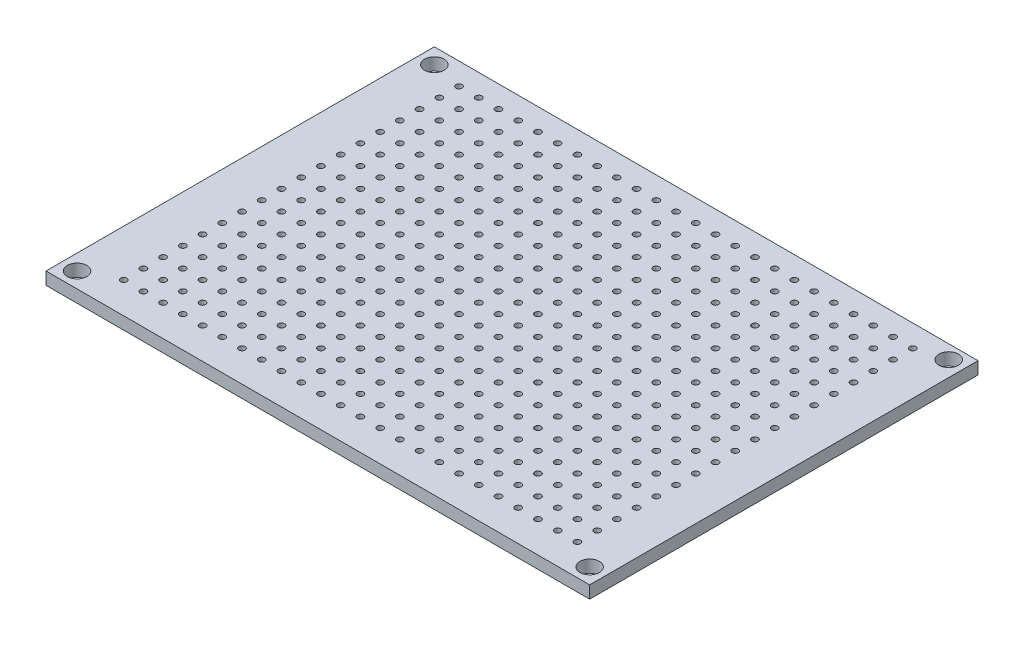
from build123d import *

# Parameters (mm, degrees)
SKETCH1_W           = 70
SKETCH1_H           = 50
BOSS_EXTRUDE1_DEPTH = 1.6
SKETCH2_R           = 1.25
SKETCH2_R_2         = 0.4
CUT_EXTRUDE1_DEPTH  = 2.6


with BuildPart() as part:
    # Sketch1 → Boss-Extrude1 (new body)
    with BuildSketch(Plane(origin=(0, 0, 0), x_dir=(1, 0, 0), z_dir=(0, 1, 0))):
        Rectangle(SKETCH1_W, SKETCH1_H)
    extrude(amount=BOSS_EXTRUDE1_DEPTH)

    # Sketch2 → Cut-Extrude1 (cut, through all)
    with BuildSketch(Plane(origin=(0, 1.6, 0), x_dir=(1, 0, 0), z_dir=(0, 1, 0))):
        with Locations((-33, 23)):
            Circle(SKETCH2_R)
        with Locations((-33, -23)):
            Circle(SKETCH2_R)
        with Locations((33, 23.22671073)):
            Circle(SKETCH2_R)
        with Locations((33, -23)):
            Circle(SKETCH2_R)
        with Locations((-29, -21)):
            Circle(SKETCH2_R_2)
        with Locations((-26.46, -21)):
            Circle(SKETCH2_R_2)
        with Locations((-23.92, -21)):
            Circle(SKETCH2_R_2)
        with Locations((-21.38, -21)):
            Circle(SKETCH2_R_2)
        with Locations((-18.84, -21)):
            Circle(SKETCH2_R_2)
        with Locations((-16.3, -21)):
            Circle(SKETCH2_R_2)
        with Locations((-13.76, -21)):
            Circle(SKETCH2_R_2)
        with Locations((-11.22, -21)):
            Circle(SKETCH2_R_2)
        with Locations((-8.68, -21)):
            Circle(SKETCH2_R_2)
        with Locations((-6.14, -21)):
            Circle(SKETCH2_R_2)
        with Locations((-3.6, -21)):
            Circle(SKETCH2_R_2)
        with Locations((-1.06, -21)):
            Circle(SKETCH2_R_2)
        with Locations((1.48, -21)):
            Circle(SKETCH2_R_2)
        with Locations((4.02, -21)):
            Circle(SKETCH2_R_2)
        with Locations((6.56, -21)):
            Circle(SKETCH2_R_2)
        with Locations((9.1, -21)):
            Circle(SKETCH2_R_2)
        with Locations((11.64, -21)):
            Circle(SKETCH2_R_2)
        with Locations((14.18, -21)):
            Circle(SKETCH2_R_2)
        with Locations((16.72, -21)):
            Circle(SKETCH2_R_2)
        with Locations((19.26, -21)):
            Circle(SKETCH2_R_2)
        with Locations((21.8, -21)):
            Circle(SKETCH2_R_2)
        with Locations((24.34, -21)):
            Circle(SKETCH2_R_2)
        with Locations((26.88, -21)):
            Circle(SKETCH2_R_2)
        with Locations((29.42, -21)):
            Circle(SKETCH2_R_2)
        with Locations((-26.46, -18.46)):
            Circle(SKETCH2_R_2)
        with Locations((-23.92, -18.46)):
            Circle(SKETCH2_R_2)
        with Locations((-21.38, -18.46)):
            Circle(SKETCH2_R_2)
        with Locations((-18.84, -18.46)):
            Circle(SKETCH2_R_2)
        with Locations((-16.3, -18.46)):
            Circle(SKETCH2_R_2)
        with Locations((-13.76, -18.46)):
            Circle(SKETCH2_R_2)
        with Locations((-11.22, -18.46)):
            Circle(SKETCH2_R_2)
        with Locations((-8.68, -18.46)):
            Circle(SKETCH2_R_2)
        with Locations((-6.14, -18.46)):
            Circle(SKETCH2_R_2)
        with Locations((-3.6, -18.46)):
            Circle(SKETCH2_R_2)
        with Locations((-1.06, -18.46)):
            Circle(SKETCH2_R_2)
        with Locations((1.48, -18.46)):
            Circle(SKETCH2_R_2)
        with Locations((4.02, -18.46)):
            Circle(SKETCH2_R_2)
        with Locations((6.56, -18.46)):
            Circle(SKETCH2_R_2)
        with Locations((9.1, -18.46)):
            Circle(SKETCH2_R_2)
        with Locations((11.64, -18.46)):
            Circle(SKETCH2_R_2)
        with Locations((14.18, -18.46)):
            Circle(SKETCH2_R_2)
        with Locations((16.72, -18.46)):
            Circle(SKETCH2_R_2)
        with Locations((19.26, -18.46)):
            Circle(SKETCH2_R_2)
        with Locations((21.8, -18.46)):
            Circle(SKETCH2_R_2)
        with Locations((24.34, -18.46)):
            Circle(SKETCH2_R_2)
        with Locations((26.88, -18.46)):
            Circle(SKETCH2_R_2)
        with Locations((29.42, -18.46)):
            Circle(SKETCH2_R_2)
        with Locations((-26.46, -15.92)):
            Circle(SKETCH2_R_2)
        with Locations((-23.92, -15.92)):
            Circle(SKETCH2_R_2)
        with Locations((-21.38, -15.92)):
            Circle(SKETCH2_R_2)
        with Locations((-18.84, -15.92)):
            Circle(SKETCH2_R_2)
        with Locations((-16.3, -15.92)):
            Circle(SKETCH2_R_2)
        with Locations((-13.76, -15.92)):
            Circle(SKETCH2_R_2)
        with Locations((-11.22, -15.92)):
            Circle(SKETCH2_R_2)
        with Locations((-8.68, -15.92)):
            Circle(SKETCH2_R_2)
        with Locations((-6.14, -15.92)):
            Circle(SKETCH2_R_2)
        with Locations((-3.6, -15.92)):
            Circle(SKETCH2_R_2)
        with Locations((-1.06, -15.92)):
            Circle(SKETCH2_R_2)
        with Locations((1.48, -15.92)):
            Circle(SKETCH2_R_2)
        with Locations((4.02, -15.92)):
            Circle(SKETCH2_R_2)
        with Locations((6.56, -15.92)):
            Circle(SKETCH2_R_2)
        with Locations((9.1, -15.92)):
            Circle(SKETCH2_R_2)
        with Locations((11.64, -15.92)):
            Circle(SKETCH2_R_2)
        with Locations((14.18, -15.92)):
            Circle(SKETCH2_R_2)
        with Locations((16.72, -15.92)):
            Circle(SKETCH2_R_2)
        with Locations((19.26, -15.92)):
            Circle(SKETCH2_R_2)
        with Locations((21.8, -15.92)):
            Circle(SKETCH2_R_2)
        with Locations((24.34, -15.92)):
            Circle(SKETCH2_R_2)
        with Locations((26.88, -15.92)):
            Circle(SKETCH2_R_2)
        with Locations((29.42, -15.92)):
            Circle(SKETCH2_R_2)
        with Locations((-26.46, -13.38)):
            Circle(SKETCH2_R_2)
        with Locations((-23.92, -13.38)):
            Circle(SKETCH2_R_2)
        with Locations((-21.38, -13.38)):
            Circle(SKETCH2_R_2)
        with Locations((-18.84, -13.38)):
            Circle(SKETCH2_R_2)
        with Locations((-16.3, -13.38)):
            Circle(SKETCH2_R_2)
        with Locations((-13.76, -13.38)):
            Circle(SKETCH2_R_2)
        with Locations((-11.22, -13.38)):
            Circle(SKETCH2_R_2)
        with Locations((-8.68, -13.38)):
            Circle(SKETCH2_R_2)
        with Locations((-6.14, -13.38)):
            Circle(SKETCH2_R_2)
        with Locations((-3.6, -13.38)):
            Circle(SKETCH2_R_2)
        with Locations((-1.06, -13.38)):
            Circle(SKETCH2_R_2)
        with Locations((1.48, -13.38)):
            Circle(SKETCH2_R_2)
        with Locations((4.02, -13.38)):
            Circle(SKETCH2_R_2)
        with Locations((6.56, -13.38)):
            Circle(SKETCH2_R_2)
        with Locations((9.1, -13.38)):
            Circle(SKETCH2_R_2)
        with Locations((11.64, -13.38)):
            Circle(SKETCH2_R_2)
        with Locations((14.18, -13.38)):
            Circle(SKETCH2_R_2)
        with Locations((16.72, -13.38)):
            Circle(SKETCH2_R_2)
        with Locations((19.26, -13.38)):
            Circle(SKETCH2_R_2)
        with Locations((21.8, -13.38)):
            Circle(SKETCH2_R_2)
        with Locations((24.34, -13.38)):
            Circle(SKETCH2_R_2)
        with Locations((26.88, -13.38)):
            Circle(SKETCH2_R_2)
        with Locations((29.42, -13.38)):
            Circle(SKETCH2_R_2)
        with Locations((-26.46, -10.84)):
            Circle(SKETCH2_R_2)
        with Locations((-23.92, -10.84)):
            Circle(SKETCH2_R_2)
        with Locations((-21.38, -10.84)):
            Circle(SKETCH2_R_2)
        with Locations((-18.84, -10.84)):
            Circle(SKETCH2_R_2)
        with Locations((-16.3, -10.84)):
            Circle(SKETCH2_R_2)
        with Locations((-13.76, -10.84)):
            Circle(SKETCH2_R_2)
        with Locations((-11.22, -10.84)):
            Circle(SKETCH2_R_2)
        with Locations((-8.68, -10.84)):
            Circle(SKETCH2_R_2)
        with Locations((-6.14, -10.84)):
            Circle(SKETCH2_R_2)
        with Locations((-3.6, -10.84)):
            Circle(SKETCH2_R_2)
        with Locations((-1.06, -10.84)):
            Circle(SKETCH2_R_2)
        with Locations((1.48, -10.84)):
            Circle(SKETCH2_R_2)
        with Locations((4.02, -10.84)):
            Circle(SKETCH2_R_2)
        with Locations((6.56, -10.84)):
            Circle(SKETCH2_R_2)
        with Locations((9.1, -10.84)):
            Circle(SKETCH2_R_2)
        with Locations((11.64, -10.84)):
            Circle(SKETCH2_R_2)
        with Locations((14.18, -10.84)):
            Circle(SKETCH2_R_2)
        with Locations((16.72, -10.84)):
            Circle(SKETCH2_R_2)
        with Locations((19.26, -10.84)):
            Circle(SKETCH2_R_2)
        with Locations((21.8, -10.84)):
            Circle(SKETCH2_R_2)
        with Locations((24.34, -10.84)):
            Circle(SKETCH2_R_2)
        with Locations((26.88, -10.84)):
            Circle(SKETCH2_R_2)
        with Locations((29.42, -10.84)):
            Circle(SKETCH2_R_2)
        with Locations((-26.46, -8.3)):
            Circle(SKETCH2_R_2)
        with Locations((-23.92, -8.3)):
            Circle(SKETCH2_R_2)
        with Locations((-21.38, -8.3)):
            Circle(SKETCH2_R_2)
        with Locations((-18.84, -8.3)):
            Circle(SKETCH2_R_2)
        with Locations((-16.3, -8.3)):
            Circle(SKETCH2_R_2)
        with Locations((-13.76, -8.3)):
            Circle(SKETCH2_R_2)
        with Locations((-11.22, -8.3)):
            Circle(SKETCH2_R_2)
        with Locations((-8.68, -8.3)):
            Circle(SKETCH2_R_2)
        with Locations((-6.14, -8.3)):
            Circle(SKETCH2_R_2)
        with Locations((-3.6, -8.3)):
            Circle(SKETCH2_R_2)
        with Locations((-1.06, -8.3)):
            Circle(SKETCH2_R_2)
        with Locations((1.48, -8.3)):
            Circle(SKETCH2_R_2)
        with Locations((4.02, -8.3)):
            Circle(SKETCH2_R_2)
        with Locations((6.56, -8.3)):
            Circle(SKETCH2_R_2)
        with Locations((9.1, -8.3)):
            Circle(SKETCH2_R_2)
        with Locations((11.64, -8.3)):
            Circle(SKETCH2_R_2)
        with Locations((14.18, -8.3)):
            Circle(SKETCH2_R_2)
        with Locations((16.72, -8.3)):
            Circle(SKETCH2_R_2)
        with Locations((19.26, -8.3)):
            Circle(SKETCH2_R_2)
        with Locations((21.8, -8.3)):
            Circle(SKETCH2_R_2)
        with Locations((24.34, -8.3)):
            Circle(SKETCH2_R_2)
        with Locations((26.88, -8.3)):
            Circle(SKETCH2_R_2)
        with Locations((29.42, -8.3)):
            Circle(SKETCH2_R_2)
        with Locations((-26.46, -5.76)):
            Circle(SKETCH2_R_2)
        with Locations((-23.92, -5.76)):
            Circle(SKETCH2_R_2)
        with Locations((-21.38, -5.76)):
            Circle(SKETCH2_R_2)
        with Locations((-18.84, -5.76)):
            Circle(SKETCH2_R_2)
        with Locations((-16.3, -5.76)):
            Circle(SKETCH2_R_2)
        with Locations((-13.76, -5.76)):
            Circle(SKETCH2_R_2)
        with Locations((-11.22, -5.76)):
            Circle(SKETCH2_R_2)
        with Locations((-8.68, -5.76)):
            Circle(SKETCH2_R_2)
        with Locations((-6.14, -5.76)):
            Circle(SKETCH2_R_2)
        with Locations((-3.6, -5.76)):
            Circle(SKETCH2_R_2)
        with Locations((-1.06, -5.76)):
            Circle(SKETCH2_R_2)
        with Locations((1.48, -5.76)):
            Circle(SKETCH2_R_2)
        with Locations((4.02, -5.76)):
            Circle(SKETCH2_R_2)
        with Locations((6.56, -5.76)):
            Circle(SKETCH2_R_2)
        with Locations((9.1, -5.76)):
            Circle(SKETCH2_R_2)
        with Locations((11.64, -5.76)):
            Circle(SKETCH2_R_2)
        with Locations((14.18, -5.76)):
            Circle(SKETCH2_R_2)
        with Locations((16.72, -5.76)):
            Circle(SKETCH2_R_2)
        with Locations((19.26, -5.76)):
            Circle(SKETCH2_R_2)
        with Locations((21.8, -5.76)):
            Circle(SKETCH2_R_2)
        with Locations((24.34, -5.76)):
            Circle(SKETCH2_R_2)
        with Locations((26.88, -5.76)):
            Circle(SKETCH2_R_2)
        with Locations((29.42, -5.76)):
            Circle(SKETCH2_R_2)
        with Locations((-26.46, -3.22)):
            Circle(SKETCH2_R_2)
        with Locations((-23.92, -3.22)):
            Circle(SKETCH2_R_2)
        with Locations((-21.38, -3.22)):
            Circle(SKETCH2_R_2)
        with Locations((-18.84, -3.22)):
            Circle(SKETCH2_R_2)
        with Locations((-16.3, -3.22)):
            Circle(SKETCH2_R_2)
        with Locations((-13.76, -3.22)):
            Circle(SKETCH2_R_2)
        with Locations((-11.22, -3.22)):
            Circle(SKETCH2_R_2)
        with Locations((-8.68, -3.22)):
            Circle(SKETCH2_R_2)
        with Locations((-6.14, -3.22)):
            Circle(SKETCH2_R_2)
        with Locations((-3.6, -3.22)):
            Circle(SKETCH2_R_2)
        with Locations((-1.06, -3.22)):
            Circle(SKETCH2_R_2)
        with Locations((1.48, -3.22)):
            Circle(SKETCH2_R_2)
        with Locations((4.02, -3.22)):
            Circle(SKETCH2_R_2)
        with Locations((6.56, -3.22)):
            Circle(SKETCH2_R_2)
        with Locations((9.1, -3.22)):
            Circle(SKETCH2_R_2)
        with Locations((11.64, -3.22)):
            Circle(SKETCH2_R_2)
        with Locations((14.18, -3.22)):
            Circle(SKETCH2_R_2)
        with Locations((16.72, -3.22)):
            Circle(SKETCH2_R_2)
        with Locations((19.26, -3.22)):
            Circle(SKETCH2_R_2)
        with Locations((21.8, -3.22)):
            Circle(SKETCH2_R_2)
        with Locations((24.34, -3.22)):
            Circle(SKETCH2_R_2)
        with Locations((26.88, -3.22)):
            Circle(SKETCH2_R_2)
        with Locations((29.42, -3.22)):
            Circle(SKETCH2_R_2)
        with Locations((-26.46, -0.68)):
            Circle(SKETCH2_R_2)
        with Locations((-23.92, -0.68)):
            Circle(SKETCH2_R_2)
        with Locations((-21.38, -0.68)):
            Circle(SKETCH2_R_2)
        with Locations((-18.84, -0.68)):
            Circle(SKETCH2_R_2)
        with Locations((-16.3, -0.68)):
            Circle(SKETCH2_R_2)
        with Locations((-13.76, -0.68)):
            Circle(SKETCH2_R_2)
        with Locations((-11.22, -0.68)):
            Circle(SKETCH2_R_2)
        with Locations((-8.68, -0.68)):
            Circle(SKETCH2_R_2)
        with Locations((-6.14, -0.68)):
            Circle(SKETCH2_R_2)
        with Locations((-3.6, -0.68)):
            Circle(SKETCH2_R_2)
        with Locations((-1.06, -0.68)):
            Circle(SKETCH2_R_2)
        with Locations((1.48, -0.68)):
            Circle(SKETCH2_R_2)
        with Locations((4.02, -0.68)):
            Circle(SKETCH2_R_2)
        with Locations((6.56, -0.68)):
            Circle(SKETCH2_R_2)
        with Locations((9.1, -0.68)):
            Circle(SKETCH2_R_2)
        with Locations((11.64, -0.68)):
            Circle(SKETCH2_R_2)
        with Locations((14.18, -0.68)):
            Circle(SKETCH2_R_2)
        with Locations((16.72, -0.68)):
            Circle(SKETCH2_R_2)
        with Locations((19.26, -0.68)):
            Circle(SKETCH2_R_2)
        with Locations((21.8, -0.68)):
            Circle(SKETCH2_R_2)
        with Locations((24.34, -0.68)):
            Circle(SKETCH2_R_2)
        with Locations((26.88, -0.68)):
            Circle(SKETCH2_R_2)
        with Locations((29.42, -0.68)):
            Circle(SKETCH2_R_2)
        with Locations((-26.46, 1.86)):
            Circle(SKETCH2_R_2)
        with Locations((-23.92, 1.86)):
            Circle(SKETCH2_R_2)
        with Locations((-21.38, 1.86)):
            Circle(SKETCH2_R_2)
        with Locations((-18.84, 1.86)):
            Circle(SKETCH2_R_2)
        with Locations((-16.3, 1.86)):
            Circle(SKETCH2_R_2)
        with Locations((-13.76, 1.86)):
            Circle(SKETCH2_R_2)
        with Locations((-11.22, 1.86)):
            Circle(SKETCH2_R_2)
        with Locations((-8.68, 1.86)):
            Circle(SKETCH2_R_2)
        with Locations((-6.14, 1.86)):
            Circle(SKETCH2_R_2)
        with Locations((-3.6, 1.86)):
            Circle(SKETCH2_R_2)
        with Locations((-1.06, 1.86)):
            Circle(SKETCH2_R_2)
        with Locations((1.48, 1.86)):
            Circle(SKETCH2_R_2)
        with Locations((4.02, 1.86)):
            Circle(SKETCH2_R_2)
        with Locations((6.56, 1.86)):
            Circle(SKETCH2_R_2)
        with Locations((9.1, 1.86)):
            Circle(SKETCH2_R_2)
        with Locations((11.64, 1.86)):
            Circle(SKETCH2_R_2)
        with Locations((14.18, 1.86)):
            Circle(SKETCH2_R_2)
        with Locations((16.72, 1.86)):
            Circle(SKETCH2_R_2)
        with Locations((19.26, 1.86)):
            Circle(SKETCH2_R_2)
        with Locations((21.8, 1.86)):
            Circle(SKETCH2_R_2)
        with Locations((24.34, 1.86)):
            Circle(SKETCH2_R_2)
        with Locations((26.88, 1.86)):
            Circle(SKETCH2_R_2)
        with Locations((29.42, 1.86)):
            Circle(SKETCH2_R_2)
        with Locations((-26.46, 4.4)):
            Circle(SKETCH2_R_2)
        with Locations((-23.92, 4.4)):
            Circle(SKETCH2_R_2)
        with Locations((-21.38, 4.4)):
            Circle(SKETCH2_R_2)
        with Locations((-18.84, 4.4)):
            Circle(SKETCH2_R_2)
        with Locations((-16.3, 4.4)):
            Circle(SKETCH2_R_2)
        with Locations((-13.76, 4.4)):
            Circle(SKETCH2_R_2)
        with Locations((-11.22, 4.4)):
            Circle(SKETCH2_R_2)
        with Locations((-8.68, 4.4)):
            Circle(SKETCH2_R_2)
        with Locations((-6.14, 4.4)):
            Circle(SKETCH2_R_2)
        with Locations((-3.6, 4.4)):
            Circle(SKETCH2_R_2)
        with Locations((-1.06, 4.4)):
            Circle(SKETCH2_R_2)
        with Locations((1.48, 4.4)):
            Circle(SKETCH2_R_2)
        with Locations((4.02, 4.4)):
            Circle(SKETCH2_R_2)
        with Locations((6.56, 4.4)):
            Circle(SKETCH2_R_2)
        with Locations((9.1, 4.4)):
            Circle(SKETCH2_R_2)
        with Locations((11.64, 4.4)):
            Circle(SKETCH2_R_2)
        with Locations((14.18, 4.4)):
            Circle(SKETCH2_R_2)
        with Locations((16.72, 4.4)):
            Circle(SKETCH2_R_2)
        with Locations((19.26, 4.4)):
            Circle(SKETCH2_R_2)
        with Locations((21.8, 4.4)):
            Circle(SKETCH2_R_2)
        with Locations((24.34, 4.4)):
            Circle(SKETCH2_R_2)
        with Locations((26.88, 4.4)):
            Circle(SKETCH2_R_2)
        with Locations((29.42, 4.4)):
            Circle(SKETCH2_R_2)
        with Locations((-26.46, 6.94)):
            Circle(SKETCH2_R_2)
        with Locations((-23.92, 6.94)):
            Circle(SKETCH2_R_2)
        with Locations((-21.38, 6.94)):
            Circle(SKETCH2_R_2)
        with Locations((-18.84, 6.94)):
            Circle(SKETCH2_R_2)
        with Locations((-16.3, 6.94)):
            Circle(SKETCH2_R_2)
        with Locations((-13.76, 6.94)):
            Circle(SKETCH2_R_2)
        with Locations((-11.22, 6.94)):
            Circle(SKETCH2_R_2)
        with Locations((-8.68, 6.94)):
            Circle(SKETCH2_R_2)
        with Locations((-6.14, 6.94)):
            Circle(SKETCH2_R_2)
        with Locations((-3.6, 6.94)):
            Circle(SKETCH2_R_2)
        with Locations((-1.06, 6.94)):
            Circle(SKETCH2_R_2)
        with Locations((1.48, 6.94)):
            Circle(SKETCH2_R_2)
        with Locations((4.02, 6.94)):
            Circle(SKETCH2_R_2)
        with Locations((6.56, 6.94)):
            Circle(SKETCH2_R_2)
        with Locations((9.1, 6.94)):
            Circle(SKETCH2_R_2)
        with Locations((11.64, 6.94)):
            Circle(SKETCH2_R_2)
        with Locations((14.18, 6.94)):
            Circle(SKETCH2_R_2)
        with Locations((16.72, 6.94)):
            Circle(SKETCH2_R_2)
        with Locations((19.26, 6.94)):
            Circle(SKETCH2_R_2)
        with Locations((21.8, 6.94)):
            Circle(SKETCH2_R_2)
        with Locations((24.34, 6.94)):
            Circle(SKETCH2_R_2)
        with Locations((26.88, 6.94)):
            Circle(SKETCH2_R_2)
        with Locations((29.42, 6.94)):
            Circle(SKETCH2_R_2)
        with Locations((-26.46, 9.48)):
            Circle(SKETCH2_R_2)
        with Locations((-23.92, 9.48)):
            Circle(SKETCH2_R_2)
        with Locations((-21.38, 9.48)):
            Circle(SKETCH2_R_2)
        with Locations((-18.84, 9.48)):
            Circle(SKETCH2_R_2)
        with Locations((-16.3, 9.48)):
            Circle(SKETCH2_R_2)
        with Locations((-13.76, 9.48)):
            Circle(SKETCH2_R_2)
        with Locations((-11.22, 9.48)):
            Circle(SKETCH2_R_2)
        with Locations((-8.68, 9.48)):
            Circle(SKETCH2_R_2)
        with Locations((-6.14, 9.48)):
            Circle(SKETCH2_R_2)
        with Locations((-3.6, 9.48)):
            Circle(SKETCH2_R_2)
        with Locations((-1.06, 9.48)):
            Circle(SKETCH2_R_2)
        with Locations((1.48, 9.48)):
            Circle(SKETCH2_R_2)
        with Locations((4.02, 9.48)):
            Circle(SKETCH2_R_2)
        with Locations((6.56, 9.48)):
            Circle(SKETCH2_R_2)
        with Locations((9.1, 9.48)):
            Circle(SKETCH2_R_2)
        with Locations((11.64, 9.48)):
            Circle(SKETCH2_R_2)
        with Locations((14.18, 9.48)):
            Circle(SKETCH2_R_2)
        with Locations((16.72, 9.48)):
            Circle(SKETCH2_R_2)
        with Locations((19.26, 9.48)):
            Circle(SKETCH2_R_2)
        with Locations((21.8, 9.48)):
            Circle(SKETCH2_R_2)
        with Locations((24.34, 9.48)):
            Circle(SKETCH2_R_2)
        with Locations((26.88, 9.48)):
            Circle(SKETCH2_R_2)
        with Locations((29.42, 9.48)):
            Circle(SKETCH2_R_2)
        with Locations((-26.46, 12.02)):
            Circle(SKETCH2_R_2)
        with Locations((-23.92, 12.02)):
            Circle(SKETCH2_R_2)
        with Locations((-21.38, 12.02)):
            Circle(SKETCH2_R_2)
        with Locations((-18.84, 12.02)):
            Circle(SKETCH2_R_2)
        with Locations((-16.3, 12.02)):
            Circle(SKETCH2_R_2)
        with Locations((-13.76, 12.02)):
            Circle(SKETCH2_R_2)
        with Locations((-11.22, 12.02)):
            Circle(SKETCH2_R_2)
        with Locations((-8.68, 12.02)):
            Circle(SKETCH2_R_2)
        with Locations((-6.14, 12.02)):
            Circle(SKETCH2_R_2)
        with Locations((-3.6, 12.02)):
            Circle(SKETCH2_R_2)
        with Locations((-1.06, 12.02)):
            Circle(SKETCH2_R_2)
        with Locations((1.48, 12.02)):
            Circle(SKETCH2_R_2)
        with Locations((4.02, 12.02)):
            Circle(SKETCH2_R_2)
        with Locations((6.56, 12.02)):
            Circle(SKETCH2_R_2)
        with Locations((9.1, 12.02)):
            Circle(SKETCH2_R_2)
        with Locations((11.64, 12.02)):
            Circle(SKETCH2_R_2)
        with Locations((14.18, 12.02)):
            Circle(SKETCH2_R_2)
        with Locations((16.72, 12.02)):
            Circle(SKETCH2_R_2)
        with Locations((19.26, 12.02)):
            Circle(SKETCH2_R_2)
        with Locations((21.8, 12.02)):
            Circle(SKETCH2_R_2)
        with Locations((24.34, 12.02)):
            Circle(SKETCH2_R_2)
        with Locations((26.88, 12.02)):
            Circle(SKETCH2_R_2)
        with Locations((29.42, 12.02)):
            Circle(SKETCH2_R_2)
        with Locations((-26.46, 14.56)):
            Circle(SKETCH2_R_2)
        with Locations((-23.92, 14.56)):
            Circle(SKETCH2_R_2)
        with Locations((-21.38, 14.56)):
            Circle(SKETCH2_R_2)
        with Locations((-18.84, 14.56)):
            Circle(SKETCH2_R_2)
        with Locations((-16.3, 14.56)):
            Circle(SKETCH2_R_2)
        with Locations((-13.76, 14.56)):
            Circle(SKETCH2_R_2)
        with Locations((-11.22, 14.56)):
            Circle(SKETCH2_R_2)
        with Locations((-8.68, 14.56)):
            Circle(SKETCH2_R_2)
        with Locations((-6.14, 14.56)):
            Circle(SKETCH2_R_2)
        with Locations((-3.6, 14.56)):
            Circle(SKETCH2_R_2)
        with Locations((-1.06, 14.56)):
            Circle(SKETCH2_R_2)
        with Locations((1.48, 14.56)):
            Circle(SKETCH2_R_2)
        with Locations((4.02, 14.56)):
            Circle(SKETCH2_R_2)
        with Locations((6.56, 14.56)):
            Circle(SKETCH2_R_2)
        with Locations((9.1, 14.56)):
            Circle(SKETCH2_R_2)
        with Locations((11.64, 14.56)):
            Circle(SKETCH2_R_2)
        with Locations((14.18, 14.56)):
            Circle(SKETCH2_R_2)
        with Locations((16.72, 14.56)):
            Circle(SKETCH2_R_2)
        with Locations((19.26, 14.56)):
            Circle(SKETCH2_R_2)
        with Locations((21.8, 14.56)):
            Circle(SKETCH2_R_2)
        with Locations((24.34, 14.56)):
            Circle(SKETCH2_R_2)
        with Locations((26.88, 14.56)):
            Circle(SKETCH2_R_2)
        with Locations((29.42, 14.56)):
            Circle(SKETCH2_R_2)
        with Locations((-26.46, 17.1)):
            Circle(SKETCH2_R_2)
        with Locations((-23.92, 17.1)):
            Circle(SKETCH2_R_2)
        with Locations((-21.38, 17.1)):
            Circle(SKETCH2_R_2)
        with Locations((-18.84, 17.1)):
            Circle(SKETCH2_R_2)
        with Locations((-16.3, 17.1)):
            Circle(SKETCH2_R_2)
        with Locations((-13.76, 17.1)):
            Circle(SKETCH2_R_2)
        with Locations((-11.22, 17.1)):
            Circle(SKETCH2_R_2)
        with Locations((-8.68, 17.1)):
            Circle(SKETCH2_R_2)
        with Locations((-6.14, 17.1)):
            Circle(SKETCH2_R_2)
        with Locations((-3.6, 17.1)):
            Circle(SKETCH2_R_2)
        with Locations((-1.06, 17.1)):
            Circle(SKETCH2_R_2)
        with Locations((1.48, 17.1)):
            Circle(SKETCH2_R_2)
        with Locations((4.02, 17.1)):
            Circle(SKETCH2_R_2)
        with Locations((6.56, 17.1)):
            Circle(SKETCH2_R_2)
        with Locations((9.1, 17.1)):
            Circle(SKETCH2_R_2)
        with Locations((11.64, 17.1)):
            Circle(SKETCH2_R_2)
        with Locations((14.18, 17.1)):
            Circle(SKETCH2_R_2)
        with Locations((16.72, 17.1)):
            Circle(SKETCH2_R_2)
        with Locations((19.26, 17.1)):
            Circle(SKETCH2_R_2)
        with Locations((21.8, 17.1)):
            Circle(SKETCH2_R_2)
        with Locations((24.34, 17.1)):
            Circle(SKETCH2_R_2)
        with Locations((26.88, 17.1)):
            Circle(SKETCH2_R_2)
        with Locations((29.42, 17.1)):
            Circle(SKETCH2_R_2)
        with Locations((-26.46, 19.64)):
            Circle(SKETCH2_R_2)
        with Locations((-23.92, 19.64)):
            Circle(SKETCH2_R_2)
        with Locations((-21.38, 19.64)):
            Circle(SKETCH2_R_2)
        with Locations((-18.84, 19.64)):
            Circle(SKETCH2_R_2)
        with Locations((-16.3, 19.64)):
            Circle(SKETCH2_R_2)
        with Locations((-13.76, 19.64)):
            Circle(SKETCH2_R_2)
        with Locations((-11.22, 19.64)):
            Circle(SKETCH2_R_2)
        with Locations((-8.68, 19.64)):
            Circle(SKETCH2_R_2)
        with Locations((-6.14, 19.64)):
            Circle(SKETCH2_R_2)
        with Locations((-3.6, 19.64)):
            Circle(SKETCH2_R_2)
        with Locations((-1.06, 19.64)):
            Circle(SKETCH2_R_2)
        with Locations((1.48, 19.64)):
            Circle(SKETCH2_R_2)
        with Locations((4.02, 19.64)):
            Circle(SKETCH2_R_2)
        with Locations((6.56, 19.64)):
            Circle(SKETCH2_R_2)
        with Locations((9.1, 19.64)):
            Circle(SKETCH2_R_2)
        with Locations((11.64, 19.64)):
            Circle(SKETCH2_R_2)
        with Locations((14.18, 19.64)):
            Circle(SKETCH2_R_2)
        with Locations((16.72, 19.64)):
            Circle(SKETCH2_R_2)
        with Locations((19.26, 19.64)):
            Circle(SKETCH2_R_2)
        with Locations((21.8, 19.64)):
            Circle(SKETCH2_R_2)
        with Locations((24.34, 19.64)):
            Circle(SKETCH2_R_2)
        with Locations((26.88, 19.64)):
            Circle(SKETCH2_R_2)
        with Locations((29.42, 19.64)):
            Circle(SKETCH2_R_2)
        with Locations((-26.46, 22.18)):
            Circle(SKETCH2_R_2)
        with Locations((-23.92, 22.18)):
            Circle(SKETCH2_R_2)
        with Locations((-21.38, 22.18)):
            Circle(SKETCH2_R_2)
        with Locations((-18.84, 22.18)):
            Circle(SKETCH2_R_2)
        with Locations((-16.3, 22.18)):
            Circle(SKETCH2_R_2)
        with Locations((-13.76, 22.18)):
            Circle(SKETCH2_R_2)
        with Locations((-11.22, 22.18)):
            Circle(SKETCH2_R_2)
        with Locations((-8.68, 22.18)):
            Circle(SKETCH2_R_2)
        with Locations((-6.14, 22.18)):
            Circle(SKETCH2_R_2)
        with Locations((-3.6, 22.18)):
            Circle(SKETCH2_R_2)
        with Locations((-1.06, 22.18)):
            Circle(SKETCH2_R_2)
        with Locations((1.48, 22.18)):
            Circle(SKETCH2_R_2)
        with Locations((4.02, 22.18)):
            Circle(SKETCH2_R_2)
        with Locations((6.56, 22.18)):
            Circle(SKETCH2_R_2)
        with Locations((9.1, 22.18)):
            Circle(SKETCH2_R_2)
        with Locations((11.64, 22.18)):
            Circle(SKETCH2_R_2)
        with Locations((14.18, 22.18)):
            Circle(SKETCH2_R_2)
        with Locations((16.72, 22.18)):
            Circle(SKETCH2_R_2)
        with Locations((19.26, 22.18)):
            Circle(SKETCH2_R_2)
        with Locations((21.8, 22.18)):
            Circle(SKETCH2_R_2)
        with Locations((24.34, 22.18)):
            Circle(SKETCH2_R_2)
        with Locations((26.88, 22.18)):
            Circle(SKETCH2_R_2)
        with Locations((29.42, 22.18)):
            Circle(SKETCH2_R_2)
        with Locations((-29, -18.46)):
            Circle(SKETCH2_R_2)
        with Locations((-29, -15.92)):
            Circle(SKETCH2_R_2)
        with Locations((-29, -13.38)):
            Circle(SKETCH2_R_2)
        with Locations((-29, -10.84)):
            Circle(SKETCH2_R_2)
        with Locations((-29, -8.3)):
            Circle(SKETCH2_R_2)
        with Locations((-29, -5.76)):
            Circle(SKETCH2_R_2)
        with Locations((-29, -3.22)):
            Circle(SKETCH2_R_2)
        with Locations((-29, -0.68)):
            Circle(SKETCH2_R_2)
        with Locations((-29, 1.86)):
            Circle(SKETCH2_R_2)
        with Locations((-29, 4.4)):
            Circle(SKETCH2_R_2)
        with Locations((-29, 6.94)):
            Circle(SKETCH2_R_2)
        with Locations((-29, 9.48)):
            Circle(SKETCH2_R_2)
        with Locations((-29, 12.02)):
            Circle(SKETCH2_R_2)
        with Locations((-29, 14.56)):
            Circle(SKETCH2_R_2)
        with Locations((-29, 17.1)):
            Circle(SKETCH2_R_2)
        with Locations((-29, 19.64)):
            Circle(SKETCH2_R_2)
        with Locations((-29, 22.18)):
            Circle(SKETCH2_R_2)
    extrude(amount=-CUT_EXTRUDE1_DEPTH, mode=Mode.SUBTRACT)


solid = part.part
